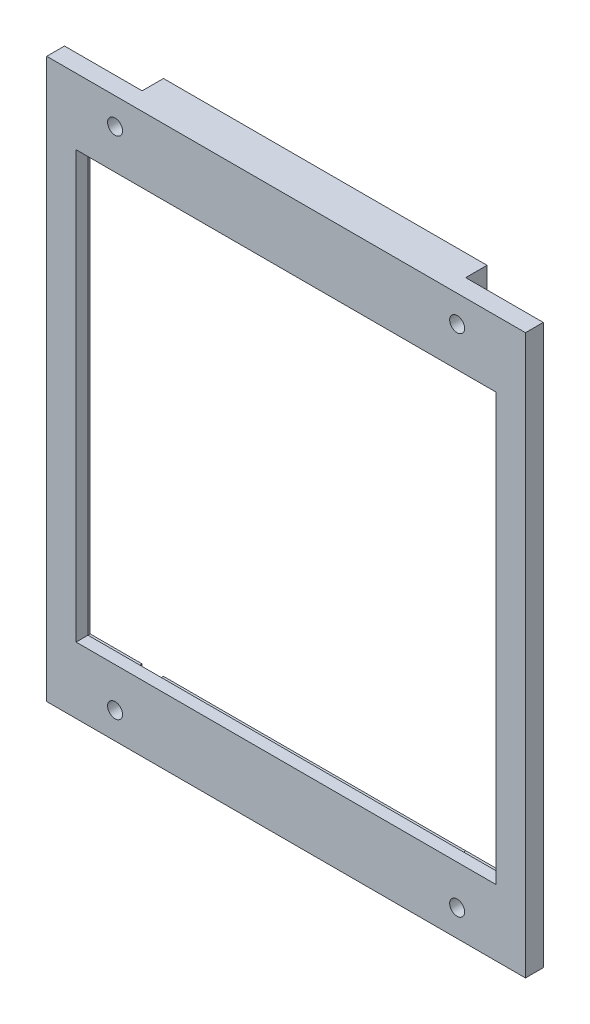
from build123d import *

# Parameters (mm, degrees)
SKETCH1_W           = 134.5
SKETCH1_H           = 157
SKETCH1_R           = 2.1
SKETCH1_W_2         = 118
SKETCH1_H_2         = 119.8
BOSS_EXTRUDE1_DEPTH = 5
CUT_EXTRUDE1_START  = -1.57
SKETCH2_W           = 90.947883714
SKETCH2_H           = 6.05
CUT_EXTRUDE1_DEPTH  = 1.57
SKETCH3_W           = 90.9
SKETCH3_H           = 11.55
BOSS_EXTRUDE2_DEPTH = 6
SKETCH4_W           = 120.05
SKETCH4_H           = 121.85
CUT_EXTRUDE2_DEPTH  = 1.65


with BuildPart() as part:
    # Sketch1 → Boss-Extrude1 (new body)
    with BuildSketch(Plane.XY.offset(6.1)):
        Rectangle(SKETCH1_W, SKETCH1_H)
        with Locations((-48.05, 70.990439644)):
            Circle(SKETCH1_R, mode=Mode.SUBTRACT)
        with Locations((48.05, 70.990439644)):
            Circle(SKETCH1_R, mode=Mode.SUBTRACT)
        with Locations((48.05, -70.990439644)):
            Circle(SKETCH1_R, mode=Mode.SUBTRACT)
        with Locations((-48.05, -70.990439644)):
            Circle(SKETCH1_R, mode=Mode.SUBTRACT)
        Rectangle(SKETCH1_W_2, SKETCH1_H_2, mode=Mode.SUBTRACT)
    extrude(amount=BOSS_EXTRUDE1_DEPTH)

    # Sketch2 → Cut-Extrude1 (cut)
    with BuildSketch(Plane(origin=(0, 0, 6.1), x_dir=(-1, 0, 0), z_dir=(0, 0, -1)).offset(CUT_EXTRUDE1_START)):
        with Locations((0.001058143, 63.925)):
            Rectangle(SKETCH2_W, SKETCH2_H)
        with Locations((0.001058143, -63.925)):
            Rectangle(SKETCH2_W, SKETCH2_H)
    extrude(amount=CUT_EXTRUDE1_DEPTH, mode=Mode.SUBTRACT)

    # Sketch3 → Boss-Extrude2 (add)
    with BuildSketch(Plane.XY.offset(0.1)):
        with Locations((0, -72.725)):
            Rectangle(SKETCH3_W, SKETCH3_H)
        with Locations((0, 72.725)):
            Rectangle(SKETCH3_W, SKETCH3_H)
    extrude(amount=BOSS_EXTRUDE2_DEPTH)

    # Sketch4 → Cut-Extrude2 (cut)
    with BuildSketch(Plane(origin=(0, 0, 6.1), x_dir=(-1, 0, 0), z_dir=(0, 0, -1))):
        Rectangle(SKETCH4_W, SKETCH4_H)
    extrude(amount=-CUT_EXTRUDE2_DEPTH, mode=Mode.SUBTRACT)


solid = part.part
